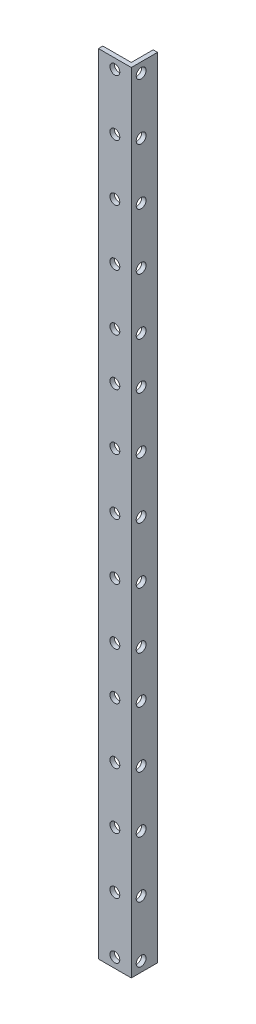
from build123d import *

# Parameters (mm, degrees)
BOSS_EXTRUDE1_DEPTH       = 360
CUT_EXTRUDE1_REACH        = 4
SKETCH2_R                 = 2.25
SKETCH3_R                 = 2.25
CUT_EXTRUDE2_DEPTH        = 2
LPATTERN1_COUNT           = 5
LPATTERN1_PITCH           = 25.65625
LPATTERN2_COUNT           = 3
LPATTERN2_PITCH           = 124.1875
LPATTERN2_COPY_1_SKETCH_R = 2.25
LPATTERN2_COPY_1_DEPTH    = 2
LPATTERN2_COPY_2_SKETCH_R = 2.25
LPATTERN2_COPY_2_DEPTH    = 2
LPATTERN2_COPY_3_SKETCH_R = 2.25
LPATTERN2_COPY_3_DEPTH    = 2
LPATTERN2_COPY_4_SKETCH_R = 2.25
LPATTERN2_COPY_4_DEPTH    = 2
LPATTERN2_COPY_5_SKETCH_R = 2.25
LPATTERN2_COPY_5_DEPTH    = 2
LPATTERN2_COPY_6_SKETCH_R = 2.25
LPATTERN2_COPY_6_DEPTH    = 2
LPATTERN2_COPY_7_SKETCH_R = 2.25
LPATTERN2_COPY_7_DEPTH    = 2
LPATTERN2_COPY_8_SKETCH_R = 2.25
LPATTERN2_COPY_8_DEPTH    = 2


with BuildPart() as part:
    # Sketch1 → Boss-Extrude1 (new body)
    with BuildSketch(Plane(origin=(0, 0, 0), x_dir=(1, 0, 0), z_dir=(0, 1, 0))):
        Polygon((0, 0), (15, 0), (15, 12), (13, 12), (13, 2), (0, 2), align=None)
    extrude(amount=BOSS_EXTRUDE1_DEPTH)

    # Sketch2 → Cut-Extrude1 (cut, up to next)
    with BuildSketch(Plane.ZY.offset(-13), mode=Mode.PRIVATE) as cut_extrude1_sk1:
        with Locations((-4.5, 329.8125)):
            Circle(SKETCH2_R)
    cut_extrude1_tool1 = extrude(cut_extrude1_sk1.sketch, amount=-CUT_EXTRUDE1_REACH, mode=Mode.PRIVATE) & part.part
    add(cut_extrude1_tool1.solids().sort_by_distance((13, 329.8125, -4.5))[0], mode=Mode.SUBTRACT)
    # Sketch2 → Cut-Extrude1 (cut, up to next)
    with BuildSketch(Plane.ZY.offset(-13), mode=Mode.PRIVATE) as cut_extrude1_sk2:
        with Locations((-4.5, 304.125)):
            Circle(SKETCH2_R)
    cut_extrude1_tool2 = extrude(cut_extrude1_sk2.sketch, amount=-CUT_EXTRUDE1_REACH, mode=Mode.PRIVATE) & part.part
    add(cut_extrude1_tool2.solids().sort_by_distance((13, 304.125, -4.5))[0], mode=Mode.SUBTRACT)
    # Sketch2 → Cut-Extrude1 (cut, up to next)
    with BuildSketch(Plane.ZY.offset(-13), mode=Mode.PRIVATE) as cut_extrude1_sk3:
        with Locations((-4.5, 278.4375)):
            Circle(SKETCH2_R)
    cut_extrude1_tool3 = extrude(cut_extrude1_sk3.sketch, amount=-CUT_EXTRUDE1_REACH, mode=Mode.PRIVATE) & part.part
    add(cut_extrude1_tool3.solids().sort_by_distance((13, 278.4375, -4.5))[0], mode=Mode.SUBTRACT)
    # Sketch2 → Cut-Extrude1 (cut, up to next)
    with BuildSketch(Plane.ZY.offset(-13), mode=Mode.PRIVATE) as cut_extrude1_sk4:
        with Locations((-4.5, 252.75)):
            Circle(SKETCH2_R)
    cut_extrude1_tool4 = extrude(cut_extrude1_sk4.sketch, amount=-CUT_EXTRUDE1_REACH, mode=Mode.PRIVATE) & part.part
    add(cut_extrude1_tool4.solids().sort_by_distance((13, 252.75, -4.5))[0], mode=Mode.SUBTRACT)
    # Sketch2 → Cut-Extrude1 (cut, up to next)
    with BuildSketch(Plane.ZY.offset(-13), mode=Mode.PRIVATE) as cut_extrude1_sk5:
        with Locations((-4.5, 231.375)):
            Circle(SKETCH2_R)
    cut_extrude1_tool5 = extrude(cut_extrude1_sk5.sketch, amount=-CUT_EXTRUDE1_REACH, mode=Mode.PRIVATE) & part.part
    add(cut_extrude1_tool5.solids().sort_by_distance((13, 231.375, -4.5))[0], mode=Mode.SUBTRACT)
    # Sketch2 → Cut-Extrude1 (cut, up to next)
    with BuildSketch(Plane.ZY.offset(-13), mode=Mode.PRIVATE) as cut_extrude1_sk6:
        with Locations((-4.5, 205.6875)):
            Circle(SKETCH2_R)
    cut_extrude1_tool6 = extrude(cut_extrude1_sk6.sketch, amount=-CUT_EXTRUDE1_REACH, mode=Mode.PRIVATE) & part.part
    add(cut_extrude1_tool6.solids().sort_by_distance((13, 205.6875, -4.5))[0], mode=Mode.SUBTRACT)
    # Sketch2 → Cut-Extrude1 (cut, up to next)
    with BuildSketch(Plane.ZY.offset(-13), mode=Mode.PRIVATE) as cut_extrude1_sk7:
        with Locations((-4.5, 180)):
            Circle(SKETCH2_R)
    cut_extrude1_tool7 = extrude(cut_extrude1_sk7.sketch, amount=-CUT_EXTRUDE1_REACH, mode=Mode.PRIVATE) & part.part
    add(cut_extrude1_tool7.solids().sort_by_distance((13, 180, -4.5))[0], mode=Mode.SUBTRACT)
    # Sketch2 → Cut-Extrude1 (cut, up to next)
    with BuildSketch(Plane.ZY.offset(-13), mode=Mode.PRIVATE) as cut_extrude1_sk8:
        with Locations((-4.5, 154.3125)):
            Circle(SKETCH2_R)
    cut_extrude1_tool8 = extrude(cut_extrude1_sk8.sketch, amount=-CUT_EXTRUDE1_REACH, mode=Mode.PRIVATE) & part.part
    add(cut_extrude1_tool8.solids().sort_by_distance((13, 154.3125, -4.5))[0], mode=Mode.SUBTRACT)
    # Sketch2 → Cut-Extrude1 (cut, up to next)
    with BuildSketch(Plane.ZY.offset(-13), mode=Mode.PRIVATE) as cut_extrude1_sk9:
        with Locations((-4.5, 128.625)):
            Circle(SKETCH2_R)
    cut_extrude1_tool9 = extrude(cut_extrude1_sk9.sketch, amount=-CUT_EXTRUDE1_REACH, mode=Mode.PRIVATE) & part.part
    add(cut_extrude1_tool9.solids().sort_by_distance((13, 128.625, -4.5))[0], mode=Mode.SUBTRACT)
    # Sketch2 → Cut-Extrude1 (cut, up to next)
    with BuildSketch(Plane.ZY.offset(-13), mode=Mode.PRIVATE) as cut_extrude1_sk10:
        with Locations((-4.5, 107.25)):
            Circle(SKETCH2_R)
    cut_extrude1_tool10 = extrude(cut_extrude1_sk10.sketch, amount=-CUT_EXTRUDE1_REACH, mode=Mode.PRIVATE) & part.part
    add(cut_extrude1_tool10.solids().sort_by_distance((13, 107.25, -4.5))[0], mode=Mode.SUBTRACT)
    # Sketch2 → Cut-Extrude1 (cut, up to next)
    with BuildSketch(Plane.ZY.offset(-13), mode=Mode.PRIVATE) as cut_extrude1_sk11:
        with Locations((-4.5, 81.5625)):
            Circle(SKETCH2_R)
    cut_extrude1_tool11 = extrude(cut_extrude1_sk11.sketch, amount=-CUT_EXTRUDE1_REACH, mode=Mode.PRIVATE) & part.part
    add(cut_extrude1_tool11.solids().sort_by_distance((13, 81.5625, -4.5))[0], mode=Mode.SUBTRACT)
    # Sketch2 → Cut-Extrude1 (cut, up to next)
    with BuildSketch(Plane.ZY.offset(-13), mode=Mode.PRIVATE) as cut_extrude1_sk12:
        with Locations((-4.5, 55.875)):
            Circle(SKETCH2_R)
    cut_extrude1_tool12 = extrude(cut_extrude1_sk12.sketch, amount=-CUT_EXTRUDE1_REACH, mode=Mode.PRIVATE) & part.part
    add(cut_extrude1_tool12.solids().sort_by_distance((13, 55.875, -4.5))[0], mode=Mode.SUBTRACT)
    # Sketch2 → Cut-Extrude1 (cut, up to next)
    with BuildSketch(Plane.ZY.offset(-13), mode=Mode.PRIVATE) as cut_extrude1_sk13:
        with Locations((-4.5, 30.1875)):
            Circle(SKETCH2_R)
    cut_extrude1_tool13 = extrude(cut_extrude1_sk13.sketch, amount=-CUT_EXTRUDE1_REACH, mode=Mode.PRIVATE) & part.part
    add(cut_extrude1_tool13.solids().sort_by_distance((13, 30.1875, -4.5))[0], mode=Mode.SUBTRACT)
    # Sketch2 → Cut-Extrude1 (cut, up to next)
    with BuildSketch(Plane.ZY.offset(-13), mode=Mode.PRIVATE) as cut_extrude1_sk14:
        with Locations((-4.5, 4.5)):
            Circle(SKETCH2_R)
    cut_extrude1_tool14 = extrude(cut_extrude1_sk14.sketch, amount=-CUT_EXTRUDE1_REACH, mode=Mode.PRIVATE) & part.part
    add(cut_extrude1_tool14.solids().sort_by_distance((13, 4.5, -4.5))[0], mode=Mode.SUBTRACT)
    # Sketch2 → Cut-Extrude1 (cut, up to next)
    with BuildSketch(Plane.ZY.offset(-13), mode=Mode.PRIVATE) as cut_extrude1_sk15:
        with Locations((-4.5, 355.5)):
            Circle(SKETCH2_R)
    cut_extrude1_tool15 = extrude(cut_extrude1_sk15.sketch, amount=-CUT_EXTRUDE1_REACH, mode=Mode.PRIVATE) & part.part
    add(cut_extrude1_tool15.solids().sort_by_distance((13, 355.5, -4.5))[0], mode=Mode.SUBTRACT)

    # Sketch3 → Cut-Extrude2 (cut)
    with BuildSketch(Plane.XY):
        with Locations((7.5, 355.5)):
            Circle(SKETCH3_R)
    cut_extrude2 = extrude(amount=-CUT_EXTRUDE2_DEPTH, mode=Mode.SUBTRACT)

    # LPattern1: Cut-Extrude2 ×5
    with Locations(*[(0, -i * LPATTERN1_PITCH, 0) for i in range(1, LPATTERN1_COUNT)]):
        add(cut_extrude2, mode=Mode.SUBTRACT)

    # LPattern2: Cut-Extrude2 ×3
    with Locations(*[(0, -i * LPATTERN2_PITCH, 0) for i in range(1, LPATTERN2_COUNT)]):
        add(cut_extrude2, mode=Mode.SUBTRACT)

    # LPattern2 copy 1 sketch → LPattern2 copy 1 (cut)
    with BuildSketch(Plane(origin=(0, -149.84375, 0), x_dir=(1, 0, 0), z_dir=(0, 0, 1))):
        with Locations((7.5, 355.5)):
            Circle(LPATTERN2_COPY_1_SKETCH_R)
    extrude(amount=-LPATTERN2_COPY_1_DEPTH, mode=Mode.SUBTRACT)

    # LPattern2 copy 2 sketch → LPattern2 copy 2 (cut)
    with BuildSketch(Plane(origin=(0, -274.03125, 0), x_dir=(1, 0, 0), z_dir=(0, 0, 1))):
        with Locations((7.5, 355.5)):
            Circle(LPATTERN2_COPY_2_SKETCH_R)
    extrude(amount=-LPATTERN2_COPY_2_DEPTH, mode=Mode.SUBTRACT)

    # LPattern2 copy 3 sketch → LPattern2 copy 3 (cut)
    with BuildSketch(Plane(origin=(0, -175.5, 0), x_dir=(1, 0, 0), z_dir=(0, 0, 1))):
        with Locations((7.5, 355.5)):
            Circle(LPATTERN2_COPY_3_SKETCH_R)
    extrude(amount=-LPATTERN2_COPY_3_DEPTH, mode=Mode.SUBTRACT)

    # LPattern2 copy 4 sketch → LPattern2 copy 4 (cut)
    with BuildSketch(Plane(origin=(0, -299.6875, 0), x_dir=(1, 0, 0), z_dir=(0, 0, 1))):
        with Locations((7.5, 355.5)):
            Circle(LPATTERN2_COPY_4_SKETCH_R)
    extrude(amount=-LPATTERN2_COPY_4_DEPTH, mode=Mode.SUBTRACT)

    # LPattern2 copy 5 sketch → LPattern2 copy 5 (cut)
    with BuildSketch(Plane(origin=(0, -201.15625, 0), x_dir=(1, 0, 0), z_dir=(0, 0, 1))):
        with Locations((7.5, 355.5)):
            Circle(LPATTERN2_COPY_5_SKETCH_R)
    extrude(amount=-LPATTERN2_COPY_5_DEPTH, mode=Mode.SUBTRACT)

    # LPattern2 copy 6 sketch → LPattern2 copy 6 (cut)
    with BuildSketch(Plane(origin=(0, -325.34375, 0), x_dir=(1, 0, 0), z_dir=(0, 0, 1))):
        with Locations((7.5, 355.5)):
            Circle(LPATTERN2_COPY_6_SKETCH_R)
    extrude(amount=-LPATTERN2_COPY_6_DEPTH, mode=Mode.SUBTRACT)

    # LPattern2 copy 7 sketch → LPattern2 copy 7 (cut)
    with BuildSketch(Plane(origin=(0, -226.8125, 0), x_dir=(1, 0, 0), z_dir=(0, 0, 1))):
        with Locations((7.5, 355.5)):
            Circle(LPATTERN2_COPY_7_SKETCH_R)
    extrude(amount=-LPATTERN2_COPY_7_DEPTH, mode=Mode.SUBTRACT)

    # LPattern2 copy 8 sketch → LPattern2 copy 8 (cut)
    with BuildSketch(Plane(origin=(0, -351, 0), x_dir=(1, 0, 0), z_dir=(0, 0, 1))):
        with Locations((7.5, 355.5)):
            Circle(LPATTERN2_COPY_8_SKETCH_R)
    extrude(amount=-LPATTERN2_COPY_8_DEPTH, mode=Mode.SUBTRACT)


solid = part.part
